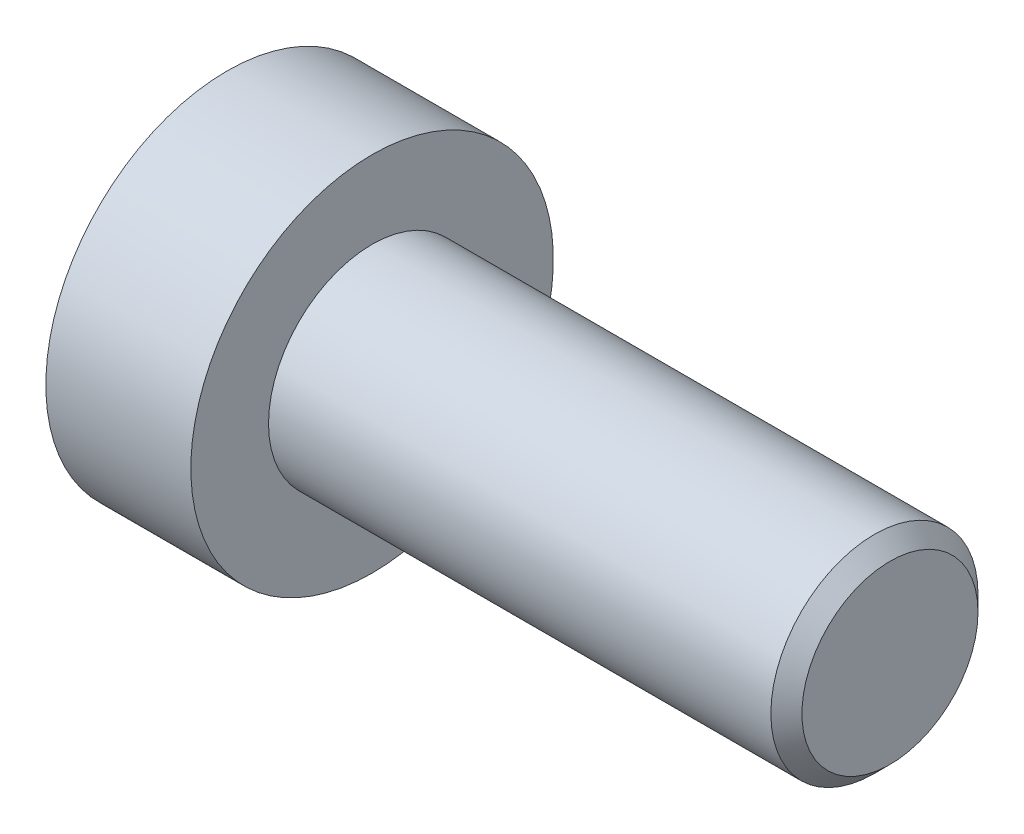
from build123d import *

# Parameters (mm, degrees)
SKETCH2_R           = 2
BOSS_EXTRUDE1_DEPTH = 10
CHAMFER1_SIZE       = 0.3
SKETCH6_W           = 2.8
SKETCH6_H           = 3.5
CUT_EXTRUDE1_DEPTH  = 1.6
SKETCH8_R           = 1.493375673
CUT_EXTRUDE2_DEPTH  = 1
CUT_EXTRUDE2_TAPER  = 45


with BuildPart() as part:
    # Sketch2 → Boss-Extrude1 (new body)
    with BuildSketch(Plane(origin=(0, 0, 0), x_dir=(0, 0, -1), z_dir=(1, 0, 0))):
        Circle(SKETCH2_R)
    extrude(amount=-BOSS_EXTRUDE1_DEPTH)

    # Chamfer1
    chamfer1_edges = [part.edges().sort_by_distance(p)[0] for p in [
        (0, 0, 2),
    ]]
    chamfer(chamfer1_edges, length=CHAMFER1_SIZE)

    # Sketch6 → Revolve1 (revolve)
    with BuildSketch(Plane.XY):
        with Locations((-11.4, 1.75)):
            Rectangle(SKETCH6_W, SKETCH6_H)
    revolve(axis=Axis((-10, 0, 0), (-1, 0, 0)))

    # Sketch7 → Cut-Extrude1 (cut)
    with BuildSketch(Plane.ZY.offset(12.8)):
        Polygon((0, 1.443375673), (-1.25, 0.721687836), (-1.25, -0.721687836), (0, -1.443375673), (1.25, -0.721687836), (1.25, 0.721687836), align=None)
    extrude(amount=-CUT_EXTRUDE1_DEPTH, mode=Mode.SUBTRACT)

    # Sketch8 → Cut-Extrude2 (cut)
    with BuildSketch(Plane.ZY.offset(12.8)):
        Circle(SKETCH8_R)
    extrude(amount=-CUT_EXTRUDE2_DEPTH, taper=CUT_EXTRUDE2_TAPER, mode=Mode.SUBTRACT)


solid = part.part
